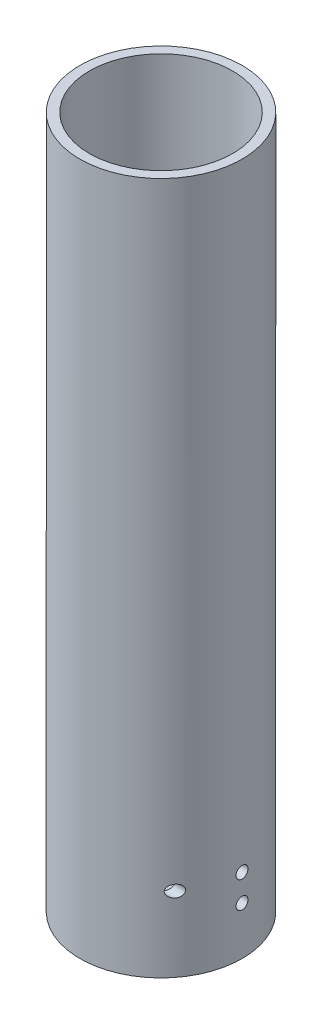
from build123d import *

# Parameters (mm, degrees)
SKETCH1_R           = 17
SKETCH1_R_2         = 15
BOSS_EXTRUDE1_DEPTH = 140
SKETCH2_R           = 17
BOSS_EXTRUDE2_DEPTH = 5
SKETCH3_R           = 1.25
CUT_EXTRUDE1_DEPTH  = 18


with BuildPart() as part:
    # Sketch1 → Boss-Extrude1 (new body)
    with BuildSketch(Plane(origin=(0, 0, 0), x_dir=(1, 0, 0), z_dir=(0, 1, 0))):
        Circle(SKETCH1_R)
        Circle(SKETCH1_R_2, mode=Mode.SUBTRACT)
    extrude(amount=BOSS_EXTRUDE1_DEPTH)

    # Sketch2 → Boss-Extrude2 (add)
    with BuildSketch(Plane.XZ):
        Circle(SKETCH2_R)
    extrude(amount=BOSS_EXTRUDE2_DEPTH)

    # Sketch3 → Cut-Extrude1 (cut, through all)
    with BuildSketch(Plane(origin=(0, 0, 0), x_dir=(0, 0, -1), z_dir=(1, 0, 0))):
        with Locations((0, 5.068906343)):
            Circle(SKETCH3_R)
        with Locations((0, 10.668906343)):
            Circle(SKETCH3_R)
        with Locations((-10.429605655, 10.668906343)):
            Circle(SKETCH3_R)
    extrude(amount=CUT_EXTRUDE1_DEPTH, mode=Mode.SUBTRACT)


solid = part.part
